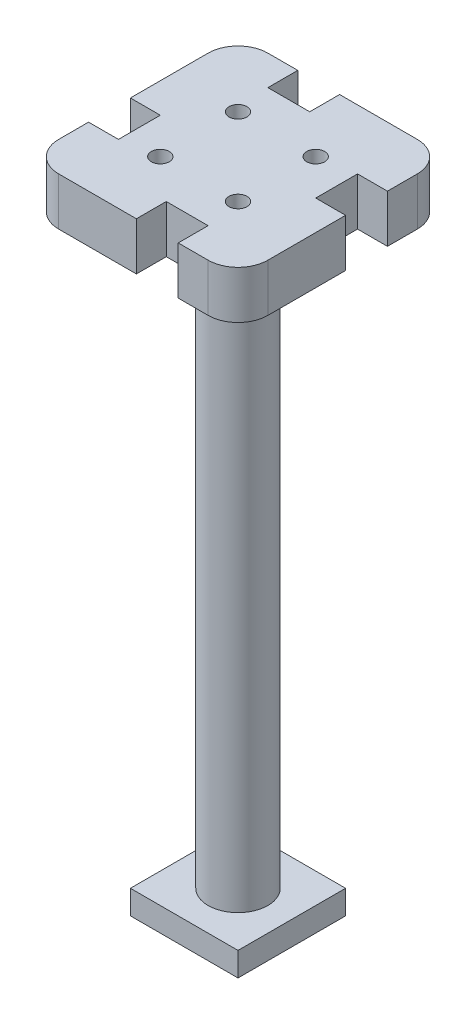
from build123d import *

# Parameters (mm, degrees)
SKETCH1_W           = 35
SKETCH1_H           = 35
BOSS_EXTRUDE1_DEPTH = 8
SKETCH2_W           = 7
SKETCH2_H           = 5
SKETCH2_W_2         = 5
SKETCH2_H_2         = 7
SKETCH2_R           = 1.5
CUT_EXTRUDE1_DEPTH  = 51.139804547
SKETCH2_5_R         = 4
SKETCH2_5_R_2       = 1.5
CUT_EXTRUDE2_DEPTH  = 4
SKETCH2_7_R         = 5
BOSS_EXTRUDE2_DEPTH = 98
SKETCH4_W           = 18
SKETCH4_H           = 18
BOSS_EXTRUDE3_DEPTH = 4
FILLET2_R           = 5


with BuildPart() as part:
    # Sketch1 → Boss-Extrude1 (new body)
    with BuildSketch(Plane(origin=(0, 0, 0), x_dir=(1, 0, 0), z_dir=(0, 1, 0))):
        with Locations((17.5, 17.5)):
            Rectangle(SKETCH1_W, SKETCH1_H)
    extrude(amount=BOSS_EXTRUDE1_DEPTH)

    # Sketch2 → Cut-Extrude1 (cut, through all)
    with BuildSketch(Plane.XZ):
        with Locations((21.5, -2.5)):
            Rectangle(SKETCH2_W, SKETCH2_H)
        with Locations((2.5, -13.5)):
            Rectangle(SKETCH2_W_2, SKETCH2_H_2)
        with Locations((32.5, -21.5)):
            Rectangle(SKETCH2_W_2, SKETCH2_H_2)
        with Locations((13.5, -32.5)):
            Rectangle(SKETCH2_W, SKETCH2_H)
        with Locations((11, -11)):
            Circle(SKETCH2_R)
        with Locations((24, -11)):
            Circle(SKETCH2_R)
        with Locations((24, -24)):
            Circle(SKETCH2_R)
        with Locations((11, -24)):
            Circle(SKETCH2_R)
    extrude(amount=-CUT_EXTRUDE1_DEPTH, mode=Mode.SUBTRACT)

    # Sketch2_5 → Cut-Extrude2 (cut)
    with BuildSketch(Plane.XZ):
        with Locations((29, -6)):
            Circle(SKETCH2_5_R)
        with Locations((6, -29)):
            Circle(SKETCH2_5_R)
        with Locations((11, -11)):
            Circle(SKETCH2_5_R_2)
    extrude(amount=-CUT_EXTRUDE2_DEPTH, mode=Mode.SUBTRACT)

    # Sketch2_7 → Boss-Extrude2 (add)
    with BuildSketch(Plane.XZ):
        with Locations((17.5, -17.5)):
            Circle(SKETCH2_7_R)
    extrude(amount=BOSS_EXTRUDE2_DEPTH)

    # Sketch4 → Boss-Extrude3 (add)
    with BuildSketch(Plane.XZ.offset(98)):
        with Locations((17.5, -17.5)):
            Rectangle(SKETCH4_W, SKETCH4_H)
    extrude(amount=BOSS_EXTRUDE3_DEPTH)

    # Fillet2
    fillet2_edges = [part.edges().sort_by_distance(p)[0] for p in [
        (35, 4, 0),
        (35, 4, -35),
        (0, 4, -35),
        (0, 4, 0),
    ]]
    fillet(fillet2_edges, radius=FILLET2_R)


solid = part.part
